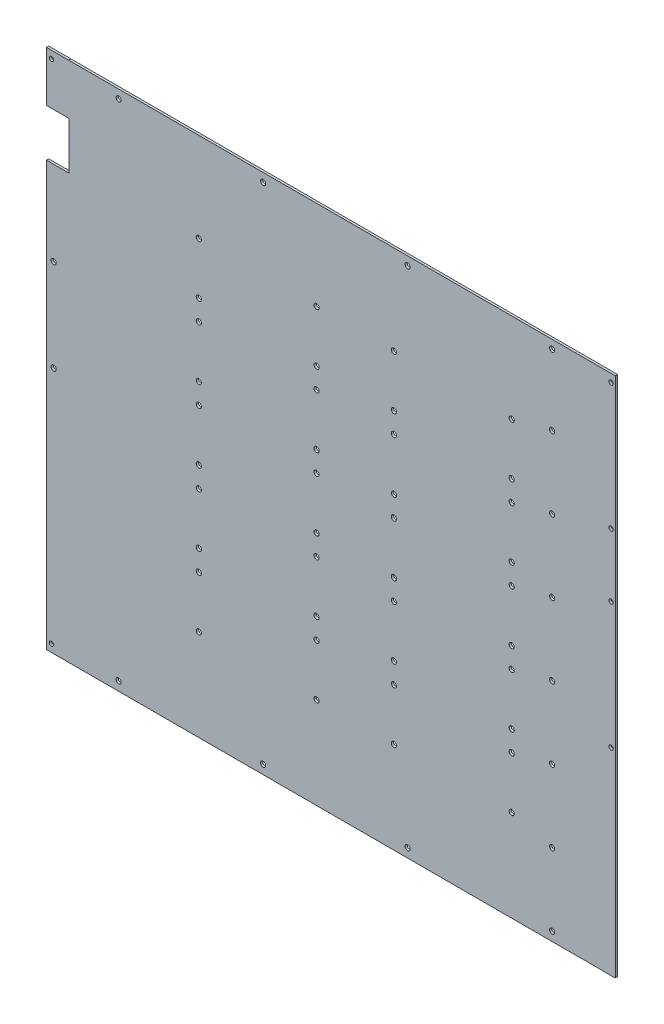
from build123d import *

# Parameters (mm, degrees)
MODEL_R             = 1.524
MODEL_R_2           = 1.8288
BOSS_EXTRUDE2_DEPTH = 1.5875


with BuildPart() as part:
    # Model → Boss-Extrude2 (new body)
    with BuildSketch(Plane.XY):
        with BuildLine():
            ThreePointArc((0, 0.0635), (0.044901281, 0.044901281), (0.0635, 0))
            Line((0.0635, 0), (399.9865, 0))
            ThreePointArc((399.9865, 0), (400.005098719, 0.044901281), (400.05, 0.0635))
            Line((400.05, 0.0635), (400.05, 366.658526))
            ThreePointArc((400.05, 366.658526), (400.005098712, 366.677124727), (399.9865, 366.722026021))
            Line((399.9865, 366.722026021), (15.703296, 366.722151979))
            ThreePointArc((15.703296, 366.722152), (15.639796, 366.658652), (15.576296, 366.722152))
            Line((15.576296, 366.722152), (0, 366.722152))
            Line((0, 366.722152), (0, 331.371648))
            Line((0, 331.371648), (15.748, 331.371648))
            Line((15.748, 331.371648), (15.748, 298.047717333))
            Line((15.748, 298.047717333), (0, 298.047717333))
            Line((0, 298.047717333), (0, 0.0635))
        make_face()
        with Locations((3.556, 5.334)):
            Circle(MODEL_R, mode=Mode.SUBTRACT)
        with Locations((50.8, 6.35)):
            Circle(MODEL_R_2, mode=Mode.SUBTRACT)
        with Locations((152.4, 6.35)):
            Circle(MODEL_R_2, mode=Mode.SUBTRACT)
        with Locations((107.188, 64.389)):
            Circle(MODEL_R_2, mode=Mode.SUBTRACT)
        with Locations((189.992, 64.389)):
            Circle(MODEL_R_2, mode=Mode.SUBTRACT)
        with Locations((5.08, 173.99)):
            Circle(MODEL_R_2, mode=Mode.SUBTRACT)
        with Locations((107.188, 100.711)):
            Circle(MODEL_R_2, mode=Mode.SUBTRACT)
        with Locations((107.188, 115.189)):
            Circle(MODEL_R_2, mode=Mode.SUBTRACT)
        with Locations((189.992, 100.711)):
            Circle(MODEL_R_2, mode=Mode.SUBTRACT)
        with Locations((189.992, 115.189)):
            Circle(MODEL_R_2, mode=Mode.SUBTRACT)
        with Locations((107.188, 151.511)):
            Circle(MODEL_R_2, mode=Mode.SUBTRACT)
        with Locations((107.188, 165.989)):
            Circle(MODEL_R_2, mode=Mode.SUBTRACT)
        with Locations((189.992, 151.511)):
            Circle(MODEL_R_2, mode=Mode.SUBTRACT)
        with Locations((189.992, 165.989)):
            Circle(MODEL_R_2, mode=Mode.SUBTRACT)
        with Locations((254, 6.35)):
            Circle(MODEL_R_2, mode=Mode.SUBTRACT)
        with Locations((244.348, 64.389)):
            Circle(MODEL_R_2, mode=Mode.SUBTRACT)
        with Locations((355.6, 6.35)):
            Circle(MODEL_R_2, mode=Mode.SUBTRACT)
        with Locations((327.152, 64.389)):
            Circle(MODEL_R_2, mode=Mode.SUBTRACT)
        with Locations((355.6, 57.15)):
            Circle(MODEL_R_2, mode=Mode.SUBTRACT)
        with Locations((244.348, 100.711)):
            Circle(MODEL_R_2, mode=Mode.SUBTRACT)
        with Locations((244.348, 115.189)):
            Circle(MODEL_R_2, mode=Mode.SUBTRACT)
        with Locations((244.348, 151.511)):
            Circle(MODEL_R_2, mode=Mode.SUBTRACT)
        with Locations((244.348, 165.989)):
            Circle(MODEL_R_2, mode=Mode.SUBTRACT)
        with Locations((327.152, 100.711)):
            Circle(MODEL_R_2, mode=Mode.SUBTRACT)
        with Locations((327.152, 115.189)):
            Circle(MODEL_R_2, mode=Mode.SUBTRACT)
        with Locations((355.6, 107.95)):
            Circle(MODEL_R_2, mode=Mode.SUBTRACT)
        with Locations((327.152, 151.511)):
            Circle(MODEL_R_2, mode=Mode.SUBTRACT)
        with Locations((327.152, 165.989)):
            Circle(MODEL_R_2, mode=Mode.SUBTRACT)
        with Locations((355.6, 158.75)):
            Circle(MODEL_R_2, mode=Mode.SUBTRACT)
        with Locations((397.0528, 138.8872)):
            Circle(MODEL_R, mode=Mode.SUBTRACT)
        with Locations((5.08, 238.76)):
            Circle(MODEL_R_2, mode=Mode.SUBTRACT)
        with Locations((107.188, 202.311)):
            Circle(MODEL_R_2, mode=Mode.SUBTRACT)
        with Locations((107.188, 216.789)):
            Circle(MODEL_R_2, mode=Mode.SUBTRACT)
        with Locations((189.992, 202.311)):
            Circle(MODEL_R_2, mode=Mode.SUBTRACT)
        with Locations((189.992, 216.789)):
            Circle(MODEL_R_2, mode=Mode.SUBTRACT)
        with Locations((107.188, 253.111)):
            Circle(MODEL_R_2, mode=Mode.SUBTRACT)
        with Locations((107.188, 267.589)):
            Circle(MODEL_R_2, mode=Mode.SUBTRACT)
        with Locations((189.992, 253.111)):
            Circle(MODEL_R_2, mode=Mode.SUBTRACT)
        with Locations((189.992, 267.589)):
            Circle(MODEL_R_2, mode=Mode.SUBTRACT)
        with Locations((3.556, 361.442)):
            Circle(MODEL_R, mode=Mode.SUBTRACT)
        with Locations((50.8, 360.68)):
            Circle(MODEL_R_2, mode=Mode.SUBTRACT)
        with Locations((107.188, 303.911)):
            Circle(MODEL_R_2, mode=Mode.SUBTRACT)
        with Locations((189.992, 303.911)):
            Circle(MODEL_R_2, mode=Mode.SUBTRACT)
        with Locations((152.4, 360.68)):
            Circle(MODEL_R_2, mode=Mode.SUBTRACT)
        with Locations((244.348, 202.311)):
            Circle(MODEL_R_2, mode=Mode.SUBTRACT)
        with Locations((244.348, 216.789)):
            Circle(MODEL_R_2, mode=Mode.SUBTRACT)
        with Locations((244.348, 253.111)):
            Circle(MODEL_R_2, mode=Mode.SUBTRACT)
        with Locations((244.348, 267.589)):
            Circle(MODEL_R_2, mode=Mode.SUBTRACT)
        with Locations((327.152, 202.311)):
            Circle(MODEL_R_2, mode=Mode.SUBTRACT)
        with Locations((327.152, 216.789)):
            Circle(MODEL_R_2, mode=Mode.SUBTRACT)
        with Locations((355.6, 209.55)):
            Circle(MODEL_R_2, mode=Mode.SUBTRACT)
        with Locations((397.0528, 227.7872)):
            Circle(MODEL_R, mode=Mode.SUBTRACT)
        with Locations((327.152, 253.111)):
            Circle(MODEL_R_2, mode=Mode.SUBTRACT)
        with Locations((327.152, 267.589)):
            Circle(MODEL_R_2, mode=Mode.SUBTRACT)
        with Locations((355.6, 260.35)):
            Circle(MODEL_R_2, mode=Mode.SUBTRACT)
        with Locations((397.0528, 272.2372)):
            Circle(MODEL_R, mode=Mode.SUBTRACT)
        with Locations((244.348, 303.911)):
            Circle(MODEL_R_2, mode=Mode.SUBTRACT)
        with Locations((254, 360.68)):
            Circle(MODEL_R_2, mode=Mode.SUBTRACT)
        with Locations((327.152, 303.911)):
            Circle(MODEL_R_2, mode=Mode.SUBTRACT)
        with Locations((355.6, 311.15)):
            Circle(MODEL_R_2, mode=Mode.SUBTRACT)
        with Locations((355.6, 360.68)):
            Circle(MODEL_R_2, mode=Mode.SUBTRACT)
        with Locations((397.0528, 361.1372)):
            Circle(MODEL_R, mode=Mode.SUBTRACT)
    extrude(amount=BOSS_EXTRUDE2_DEPTH)


solid = part.part
